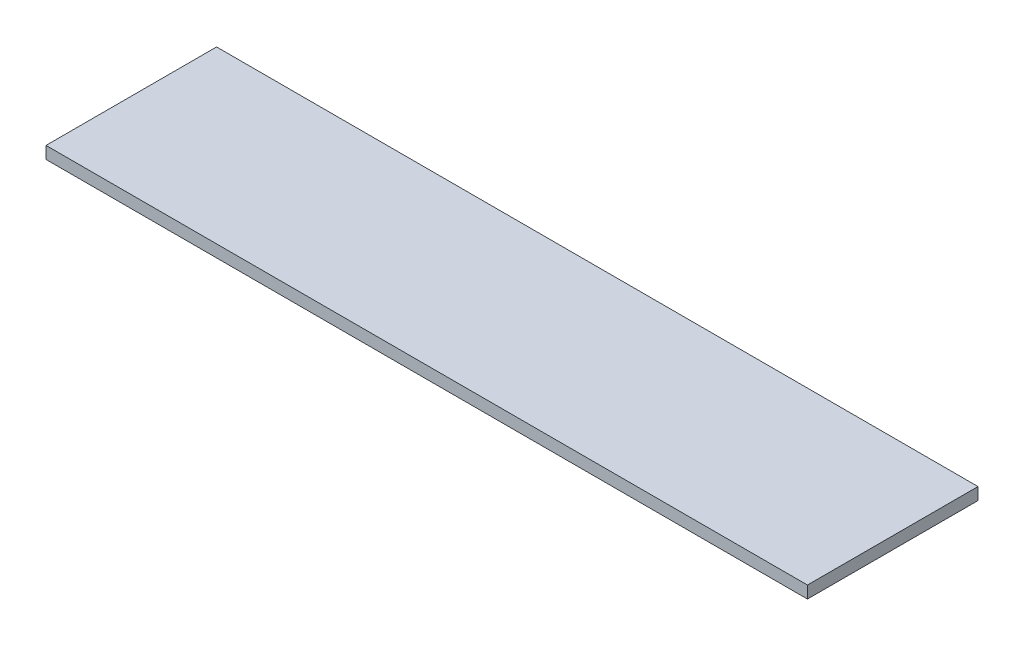
from build123d import *

# Parameters (mm, degrees)
SKETCH1_W           = 125
SKETCH1_H           = 28
BOSS_EXTRUDE1_DEPTH = 2


with BuildPart() as part:
    # Sketch1 → Boss-Extrude1 (new body)
    with BuildSketch(Plane(origin=(0, 0, 0), x_dir=(1, 0, 0), z_dir=(0, 1, 0))):
        with Locations((37.27992793, 11.39213657)):
            Rectangle(SKETCH1_W, SKETCH1_H)
    extrude(amount=BOSS_EXTRUDE1_DEPTH)


solid = part.part
